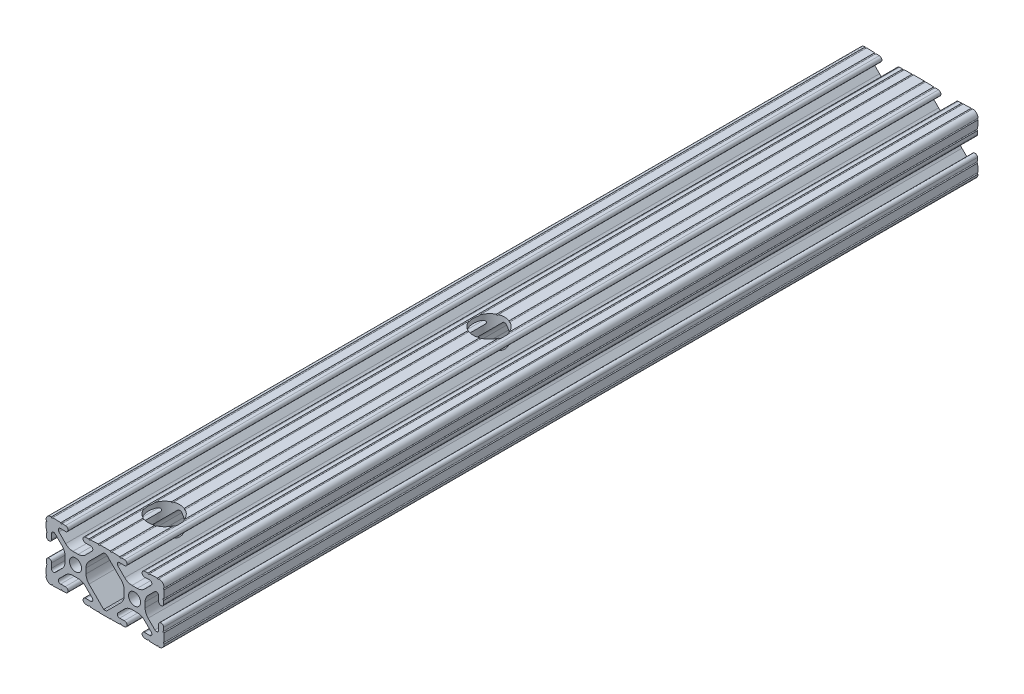
from build123d import *

# Parameters (mm, degrees)
SKETCH3_R          = 2.6035
EXTRUDE1_DEPTH     = 350
SKETCH4_R          = 6.75
CUT_EXTRUDE2_DEPTH = 26.39865385


with BuildPart() as part:
    # Sketch3 → Extrude1 (new body)
    with BuildSketch(Plane.XY):
        with BuildLine():
            Line((-1.115277175, 4.5085), (1.115277175, 4.5085))
            ThreePointArc((1.115277175, 4.5085), (2.806584872, 4.844922018), (4.240406305, 5.80297087))
            Line((4.240406305, 5.80297087), (7.148423664, 8.710988229))
            ThreePointArc((7.148423664, 8.710988229), (7.349906316, 9.772227925), (6.436353897, 10.348636575))
            Line((6.436353897, 10.348636575), (4.381960454, 10.276895575))
            ThreePointArc((4.381960454, 10.276895575), (3.239173075, 11.342562046), (4.304839546, 12.485349424))
            Line((4.304839546, 12.485349424), (5.728246175, 12.535055879))
            ThreePointArc((5.728246175, 12.535055879), (6.054756855, 12.230579745), (6.35923299, 12.557090424))
            Line((6.35923299, 12.557090424), (9.782092278, 12.676619304))
            ThreePointArc((9.782092278, 12.676619304), (10.108602958, 12.37214317), (10.413079092, 12.69865385))
            Line((10.413079092, 12.69865385), (14.986920908, 12.69865385))
            ThreePointArc((14.986920908, 12.69865385), (15.291397042, 12.37214317), (15.617907722, 12.676619304))
            Line((15.617907722, 12.676619304), (19.04076701, 12.557090424))
            ThreePointArc((19.04076701, 12.557090424), (19.345243145, 12.230579745), (19.671753825, 12.535055879))
            Line((19.671753825, 12.535055879), (21.095160454, 12.485349424))
            ThreePointArc((21.095160454, 12.485349424), (22.160826925, 11.342562046), (21.018039546, 10.276895575))
            Line((21.018039546, 10.276895575), (18.963646103, 10.348636575))
            ThreePointArc((18.963646103, 10.348636575), (18.050093684, 9.772227925), (18.251576336, 8.710988229))
            Line((18.251576336, 8.710988229), (21.159593695, 5.80297087))
            ThreePointArc((21.159593695, 5.80297087), (22.593415128, 4.844922018), (24.284722825, 4.5085))
            Line((24.284722825, 4.5085), (26.515277175, 4.5085))
            ThreePointArc((26.515277175, 4.5085), (28.206584872, 4.844922018), (29.640406305, 5.80297087))
            Line((29.640406305, 5.80297087), (32.548423664, 8.710988229))
            ThreePointArc((32.548423664, 8.710988229), (32.749906316, 9.772227925), (31.836353897, 10.348636575))
            Line((31.836353897, 10.348636575), (29.781960454, 10.276895575))
            ThreePointArc((29.781960454, 10.276895575), (28.639173075, 11.342562046), (29.704839546, 12.485349424))
            Line((29.704839546, 12.485349424), (31.128246175, 12.535055879))
            ThreePointArc((31.128246175, 12.535055879), (31.454756855, 12.230579745), (31.75923299, 12.557090424))
            Line((31.75923299, 12.557090424), (35.182092278, 12.676619304))
            ThreePointArc((35.182092278, 12.676619304), (35.508602958, 12.37214317), (35.813079092, 12.69865385))
            ThreePointArc((35.813079092, 12.69865385), (37.452764565, 12.052764565), (38.09865385, 10.413079092))
            ThreePointArc((38.09865385, 10.413079092), (37.77214317, 10.108602958), (38.076619304, 9.782092278))
            Line((38.076619304, 9.782092278), (37.957090424, 6.35923299))
            ThreePointArc((37.957090424, 6.35923299), (37.630579745, 6.054756855), (37.935055879, 5.728246175))
            Line((37.935055879, 5.728246175), (37.885349424, 4.304839546))
            ThreePointArc((37.885349424, 4.304839546), (36.742562046, 3.239173075), (35.676895575, 4.381960454))
            Line((35.676895575, 4.381960454), (35.748636575, 6.436353897))
            ThreePointArc((35.748636575, 6.436353897), (35.172227925, 7.349906316), (34.110988229, 7.148423664))
            Line((34.110988229, 7.148423664), (31.202970856, 4.240406291))
            ThreePointArc((31.202970856, 4.240406291), (30.244922014, 2.806584863), (29.9085, 1.115277175))
            Line((29.9085, 1.115277175), (29.9085, -1.115277175))
            ThreePointArc((29.9085, -1.115277175), (30.244922014, -2.806584863), (31.202970856, -4.240406291))
            Line((31.202970856, -4.240406291), (34.110988229, -7.148423664))
            ThreePointArc((34.110988229, -7.148423664), (35.172227925, -7.349906316), (35.748636575, -6.436353897))
            Line((35.748636575, -6.436353897), (35.676895575, -4.381960454))
            ThreePointArc((35.676895575, -4.381960454), (36.742562046, -3.239173075), (37.885349424, -4.304839546))
            Line((37.885349424, -4.304839546), (37.935055879, -5.728246175))
            ThreePointArc((37.935055879, -5.728246175), (37.630579745, -6.054756855), (37.957090424, -6.35923299))
            Line((37.957090424, -6.35923299), (38.076619304, -9.782092278))
            ThreePointArc((38.076619304, -9.782092278), (37.77214317, -10.108602958), (38.09865385, -10.413079092))
            ThreePointArc((38.09865385, -10.413079092), (37.452764565, -12.052764565), (35.813079092, -12.69865385))
            ThreePointArc((35.813079092, -12.69865385), (35.508602958, -12.37214317), (35.182092278, -12.676619304))
            Line((35.182092278, -12.676619304), (31.75923299, -12.557090424))
            ThreePointArc((31.75923299, -12.557090424), (31.454756855, -12.230579745), (31.128246175, -12.535055879))
            Line((31.128246175, -12.535055879), (29.704839546, -12.485349424))
            ThreePointArc((29.704839546, -12.485349424), (28.639173075, -11.342562046), (29.781960454, -10.276895575))
            Line((29.781960454, -10.276895575), (31.836353897, -10.348636575))
            ThreePointArc((31.836353897, -10.348636575), (32.749906316, -9.772227925), (32.548423664, -8.710988229))
            Line((32.548423664, -8.710988229), (29.640406305, -5.80297087))
            ThreePointArc((29.640406305, -5.80297087), (28.206584872, -4.844922018), (26.515277175, -4.5085))
            Line((26.515277175, -4.5085), (24.284722825, -4.5085))
            ThreePointArc((24.284722825, -4.5085), (22.593415128, -4.844922018), (21.159593695, -5.80297087))
            Line((21.159593695, -5.80297087), (18.251576336, -8.710988229))
            ThreePointArc((18.251576336, -8.710988229), (18.050093684, -9.772227925), (18.963646103, -10.348636575))
            Line((18.963646103, -10.348636575), (21.018039546, -10.276895575))
            ThreePointArc((21.018039546, -10.276895575), (22.160826925, -11.342562046), (21.095160454, -12.485349424))
            Line((21.095160454, -12.485349424), (19.671753825, -12.535055879))
            ThreePointArc((19.671753825, -12.535055879), (19.345243145, -12.230579745), (19.04076701, -12.557090424))
            Line((19.04076701, -12.557090424), (15.617907722, -12.676619304))
            ThreePointArc((15.617907722, -12.676619304), (15.291397042, -12.37214317), (14.986920908, -12.69865385))
            Line((14.986920908, -12.69865385), (10.413079092, -12.69865385))
            ThreePointArc((10.413079092, -12.69865385), (10.108602958, -12.37214317), (9.782092278, -12.676619304))
            Line((9.782092278, -12.676619304), (6.35923299, -12.557090424))
            ThreePointArc((6.35923299, -12.557090424), (6.054756855, -12.230579745), (5.728246175, -12.535055879))
            Line((5.728246175, -12.535055879), (4.304839546, -12.485349424))
            ThreePointArc((4.304839546, -12.485349424), (3.239173075, -11.342562046), (4.381960454, -10.276895575))
            Line((4.381960454, -10.276895575), (6.436353897, -10.348636575))
            ThreePointArc((6.436353897, -10.348636575), (7.349906316, -9.772227925), (7.148423664, -8.710988229))
            Line((7.148423664, -8.710988229), (4.240406305, -5.80297087))
            ThreePointArc((4.240406305, -5.80297087), (2.806584872, -4.844922018), (1.115277175, -4.5085))
            Line((1.115277175, -4.5085), (-1.115277175, -4.5085))
            ThreePointArc((-1.115277175, -4.5085), (-2.806584872, -4.844922018), (-4.240406305, -5.80297087))
            Line((-4.240406305, -5.80297087), (-7.148423664, -8.710988229))
            ThreePointArc((-7.148423664, -8.710988229), (-7.349906316, -9.772227925), (-6.436353897, -10.348636575))
            Line((-6.436353897, -10.348636575), (-4.381960454, -10.276895575))
            ThreePointArc((-4.381960454, -10.276895575), (-3.239173075, -11.342562046), (-4.304839546, -12.485349424))
            Line((-4.304839546, -12.485349424), (-5.728246175, -12.535055879))
            ThreePointArc((-5.728246175, -12.535055879), (-6.054756855, -12.230579745), (-6.35923299, -12.557090424))
            Line((-6.35923299, -12.557090424), (-9.782092278, -12.676619304))
            ThreePointArc((-9.782092278, -12.676619304), (-10.108602958, -12.37214317), (-10.413079092, -12.69865385))
            ThreePointArc((-10.413079092, -12.69865385), (-12.052764565, -12.052764565), (-12.69865385, -10.413079092))
            ThreePointArc((-12.69865385, -10.413079092), (-12.37214317, -10.108602958), (-12.676619304, -9.782092278))
            Line((-12.676619304, -9.782092278), (-12.557090424, -6.35923299))
            ThreePointArc((-12.557090424, -6.35923299), (-12.230579745, -6.054756855), (-12.535055879, -5.728246175))
            Line((-12.535055879, -5.728246175), (-12.485349424, -4.304839546))
            ThreePointArc((-12.485349424, -4.304839546), (-11.342562046, -3.239173075), (-10.276895575, -4.381960454))
            Line((-10.276895575, -4.381960454), (-10.348636575, -6.436353897))
            ThreePointArc((-10.348636575, -6.436353897), (-9.772227925, -7.349906316), (-8.710988229, -7.148423664))
            Line((-8.710988229, -7.148423664), (-5.802970856, -4.240406291))
            ThreePointArc((-5.802970856, -4.240406291), (-4.844922014, -2.806584863), (-4.5085, -1.115277175))
            Line((-4.5085, -1.115277175), (-4.5085, 1.115277175))
            ThreePointArc((-4.5085, 1.115277175), (-4.844922014, 2.806584863), (-5.802970856, 4.240406291))
            Line((-5.802970856, 4.240406291), (-8.710988229, 7.148423664))
            ThreePointArc((-8.710988229, 7.148423664), (-9.772227925, 7.349906316), (-10.348636575, 6.436353897))
            Line((-10.348636575, 6.436353897), (-10.276895575, 4.381960454))
            ThreePointArc((-10.276895575, 4.381960454), (-11.342562046, 3.239173075), (-12.485349424, 4.304839546))
            Line((-12.485349424, 4.304839546), (-12.535055879, 5.728246175))
            ThreePointArc((-12.535055879, 5.728246175), (-12.230579745, 6.054756855), (-12.557090424, 6.35923299))
            Line((-12.557090424, 6.35923299), (-12.676619304, 9.782092278))
            ThreePointArc((-12.676619304, 9.782092278), (-12.37214317, 10.108602958), (-12.69865385, 10.413079092))
            ThreePointArc((-12.69865385, 10.413079092), (-12.052764565, 12.052764565), (-10.413079092, 12.69865385))
            ThreePointArc((-10.413079092, 12.69865385), (-10.108602958, 12.37214317), (-9.782092278, 12.676619304))
            Line((-9.782092278, 12.676619304), (-6.35923299, 12.557090424))
            ThreePointArc((-6.35923299, 12.557090424), (-6.054756855, 12.230579745), (-5.728246175, 12.535055879))
            Line((-5.728246175, 12.535055879), (-4.304839546, 12.485349424))
            ThreePointArc((-4.304839546, 12.485349424), (-3.239173075, 11.342562046), (-4.381960454, 10.276895575))
            Line((-4.381960454, 10.276895575), (-6.436353897, 10.348636575))
            ThreePointArc((-6.436353897, 10.348636575), (-7.349906316, 9.772227925), (-7.148423664, 8.710988229))
            Line((-7.148423664, 8.710988229), (-4.240406305, 5.80297087))
            ThreePointArc((-4.240406305, 5.80297087), (-2.806584872, 4.844922018), (-1.115277175, 4.5085))
        make_face()
        with Locations((25.4, 0)):
            Circle(SKETCH3_R, mode=Mode.SUBTRACT)
        Circle(SKETCH3_R, mode=Mode.SUBTRACT)
        with BuildLine():
            Line((5.802970856, 4.240406291), (12.109304956, 10.546740391))
            Line((12.109304956, 10.546740391), (12.7, 10.567367916))
            Line((12.7, 10.567367916), (13.290695044, 10.546740391))
            Line((13.290695044, 10.546740391), (19.597029144, 4.240406291))
            ThreePointArc((19.597029144, 4.240406291), (20.555077986, 2.806584863), (20.8915, 1.115277175))
            Line((20.8915, 1.115277175), (20.8915, -1.115277175))
            ThreePointArc((20.8915, -1.115277175), (20.555077986, -2.806584863), (19.597029144, -4.240406291))
            Line((19.597029144, -4.240406291), (13.290695044, -10.546740391))
            Line((13.290695044, -10.546740391), (12.7, -10.567367916))
            Line((12.7, -10.567367916), (12.109304956, -10.546740391))
            Line((12.109304956, -10.546740391), (5.802970856, -4.240406291))
            ThreePointArc((5.802970856, -4.240406291), (4.844922014, -2.806584863), (4.5085, -1.115277175))
            Line((4.5085, -1.115277175), (4.5085, 1.115277175))
            ThreePointArc((4.5085, 1.115277175), (4.844922014, 2.806584863), (5.802970856, 4.240406291))
        make_face(mode=Mode.SUBTRACT)
    extrude(amount=EXTRUDE1_DEPTH)

    # Sketch4 → Cut-Extrude2 (cut, through all)
    with BuildSketch(Plane(origin=(0, 12.69865385, 0), x_dir=(1, 0, 0), z_dir=(0, 1, 0))):
        with Locations((12.7, -324.6)):
            Circle(SKETCH4_R)
        with Locations((12.7, -184.9)):
            Circle(SKETCH4_R)
    extrude(amount=-CUT_EXTRUDE2_DEPTH, mode=Mode.SUBTRACT)


solid = part.part
